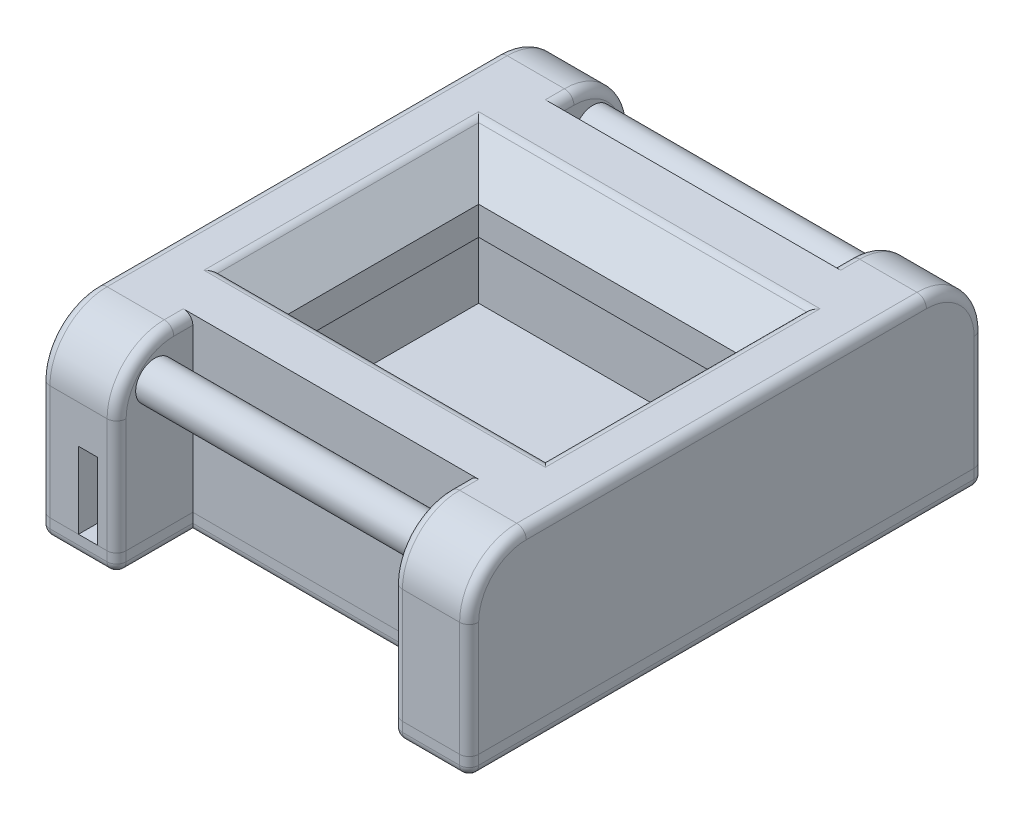
from build123d import *

# Parameters (mm, degrees)
SKETCH1_W           = 27
SKETCH1_H           = 20
OLED_FACE_DEPTH     = 7
OLED_INDENT_SIZE    = 4
SKETCH4_W           = 15
SKETCH4_H           = 3
CUT_EXTRUDE1_DEPTH  = 2
FILLET3_R           = 6
BOSS_EXTRUDE4_REACH = 47
SKETCH5_R           = 2
SKETCH6_W           = 29
SKETCH6_H           = 4
BOSS_EXTRUDE7_DEPTH = 11
OLED_BOTTOM_DEPTH   = 2
SKETCH9_W           = 2
SKETCH9_H           = 12
CUT_EXTRUDE2_DEPTH  = 8
FILLET4_R           = 1
FILLET5_R           = 1
FILLET6_R           = 1


with BuildPart() as part:
    # Sketch1 → OLED_Face (new body)
    with BuildSketch(Plane(origin=(0, 0, 0), x_dir=(1, 0, 0), z_dir=(0, 1, 0))):
        Polygon((14.5, 19), (-14.5, 19), (-14.5, 27), (-22.5, 27), (-22.5, -27), (-14.5, -27), (-14.5, -19), (14.5, -19), (14.5, -27), (22.5, -27), (22.5, 27), (14.5, 27), align=None)
        Rectangle(SKETCH1_W, SKETCH1_H, mode=Mode.SUBTRACT)
    extrude(amount=OLED_FACE_DEPTH)

    # OLED_Indent
    oled_indent_edges = [part.edges().sort_by_distance(p)[0] for p in [
        (0, 7, -10),
        (13.5, 7, 0),
        (0, 7, 10),
        (-13.5, 7, 0),
    ]]
    chamfer(oled_indent_edges, length=OLED_INDENT_SIZE)

    # Sketch4 → Cut-Extrude1 (cut)
    with BuildSketch(Plane.XZ):
        with Locations((0, -13)):
            Rectangle(SKETCH4_W, SKETCH4_H)
    extrude(amount=-CUT_EXTRUDE1_DEPTH, mode=Mode.SUBTRACT)

    # Fillet3
    fillet3_edges = [part.edges().sort_by_distance(p)[0] for p in [
        (-18.5, 7, -27),
        (18.5, 7, -27),
        (-18.5, 7, 27),
        (18.5, 7, 27),
    ]]
    fillet(fillet3_edges, radius=FILLET3_R)

    # Sketch5 → Boss-Extrude4 (add, up to next)
    with BuildSketch(Plane(origin=(22.5, 0, 0), x_dir=(0, 0, -1), z_dir=(1, 0, 0)), mode=Mode.PRIVATE) as boss_extrude4_sk1:
        with Locations((-23, 3)):
            Circle(SKETCH5_R)
    boss_extrude4_tool1 = extrude(boss_extrude4_sk1.sketch, amount=-BOSS_EXTRUDE4_REACH, mode=Mode.PRIVATE) - part.part
    add(boss_extrude4_tool1.solids().sort_by_distance((22.5, 3, 23))[0])
    # Sketch5 → Boss-Extrude4 (add, up to next)
    with BuildSketch(Plane(origin=(22.5, 0, 0), x_dir=(0, 0, -1), z_dir=(1, 0, 0)), mode=Mode.PRIVATE) as boss_extrude4_sk2:
        with Locations((23, 3)):
            Circle(SKETCH5_R)
    boss_extrude4_tool2 = extrude(boss_extrude4_sk2.sketch, amount=-BOSS_EXTRUDE4_REACH, mode=Mode.PRIVATE) - part.part
    add(boss_extrude4_tool2.solids().sort_by_distance((22.5, 3, -23))[0])

    # Sketch6 → Boss-Extrude7 (add)
    with BuildSketch(Plane.XZ):
        Polygon((-14.5, 19), (-14.5, 27), (-22.5, 27), (-22.5, -27), (-14.5, -27), (-14.5, -19), (-14.5, -15), (-18.5, -15), (-18.5, 15), (-14.5, 15), align=None)
        Polygon((14.5, -15), (18.5, -15), (18.5, 15), (14.5, 15), (14.5, 19), (14.5, 27), (22.5, 27), (22.5, -27), (14.5, -27), (14.5, -19), align=None)
        with Locations((0, 17)):
            Rectangle(SKETCH6_W, SKETCH6_H)
        with Locations((0, -17)):
            Rectangle(SKETCH6_W, SKETCH6_H)
    extrude(amount=BOSS_EXTRUDE7_DEPTH)

    # Sketch9 → Cut-Extrude2 (cut)
    with BuildSketch(Plane.XZ.offset(11)):
        with Locations((-17.5, 21)):
            Rectangle(SKETCH9_W, SKETCH9_H)
    extrude(amount=-CUT_EXTRUDE2_DEPTH, mode=Mode.SUBTRACT)

    # Fillet5
    fillet5_edges = [part.edges().sort_by_distance(p)[0] for p in [
        (22.5, 7, 0),
        (-22.5, 7, 0),
        (14.5, -5, -27),
        (14.5, 5.242640687, -25.242640687),
        (22.5, -5, -27),
        (22.5, -5, 27),
        (22.5, 5.242640687, 25.242640687),
        (22.5, 5.242640687, -25.242640687),
        (-22.5, -5, -27),
        (-14.5, -5, -27),
        (-14.5, 5.242640687, -25.242640687),
        (-22.5, -5, 27),
        (-22.5, 5.242640687, 25.242640687),
        (-22.5, 5.242640687, -25.242640687),
        (14.5, -5, 27),
        (14.5, 5.242640687, 25.242640687),
        (-14.5, -5, 27),
        (-14.5, 5.242640687, 25.242640687),
        (-14.5, 7, -20),
        (14.5, 7, -20),
        (-14.5, 7, 20),
        (14.5, 7, 20),
    ]]
    fillet(fillet5_edges, radius=FILLET5_R)

    # Fillet6
    fillet6_edges = [part.edges().sort_by_distance(p)[0] for p in [
        (0, 7, -14),
        (-17.5, 7, 0),
        (17.5, 7, 0),
        (0, 7, 14),
    ]]
    fillet(fillet6_edges, radius=FILLET6_R)


with BuildPart() as body_2:
    # Sketch8 → OLED_Bottom (new body)
    with BuildSketch(Plane.XZ.offset(11)):
        Polygon((-22.5, 27), (-22.5, -27), (-14.5, -27), (-14.5, -19), (14.5, -19), (14.5, -27), (22.5, -27), (22.5, 27), (14.5, 27), (14.5, 19), (-14.5, 19), (-14.5, 27), align=None)
    extrude(amount=OLED_BOTTOM_DEPTH)

    # Fillet4
    fillet4_edges = [body_2.edges().sort_by_distance(p)[0] for p in [
        (22.5, -13, 0),
        (18.5, -13, 27),
        (-14.5, -12, -27),
        (14.5, -13, 23),
        (-22.5, -12, -27),
        (-22.5, -12, 27),
        (-14.5, -12, 27),
        (14.5, -12, 27),
        (22.5, -12, 27),
        (22.5, -12, -27),
        (14.5, -12, -27),
        (0, -13, 19),
        (-14.5, -13, 23),
        (-18.5, -13, 27),
        (-22.5, -13, 0),
        (-18.5, -13, -27),
        (-14.5, -13, -23),
        (0, -13, -19),
        (14.5, -13, -23),
        (18.5, -13, -27),
    ]]
    fillet(fillet4_edges, radius=FILLET4_R)


solid = Compound([part.part, body_2.part])
